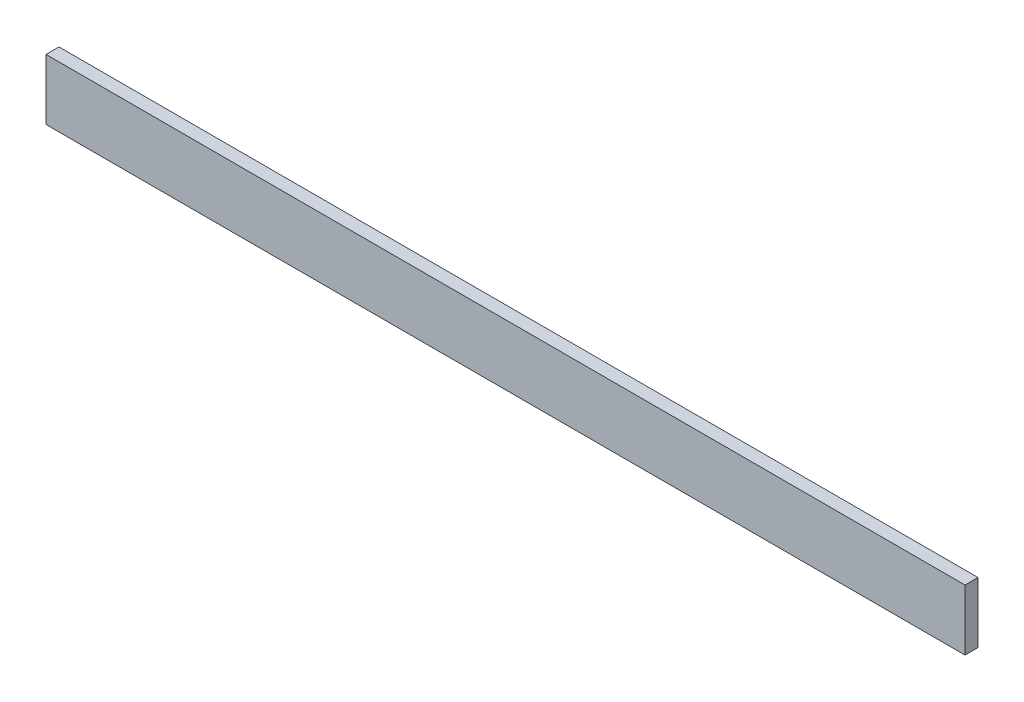
from build123d import *

# Parameters (mm, degrees)
SKETCH1_W           = 106
SKETCH1_H           = 7
BOSS_EXTRUDE1_DEPTH = 1.5


with BuildPart() as part:
    # Sketch1 → Boss-Extrude1 (new body)
    with BuildSketch(Plane.XY):
        Rectangle(SKETCH1_W, SKETCH1_H)
    extrude(amount=BOSS_EXTRUDE1_DEPTH)


solid = part.part
